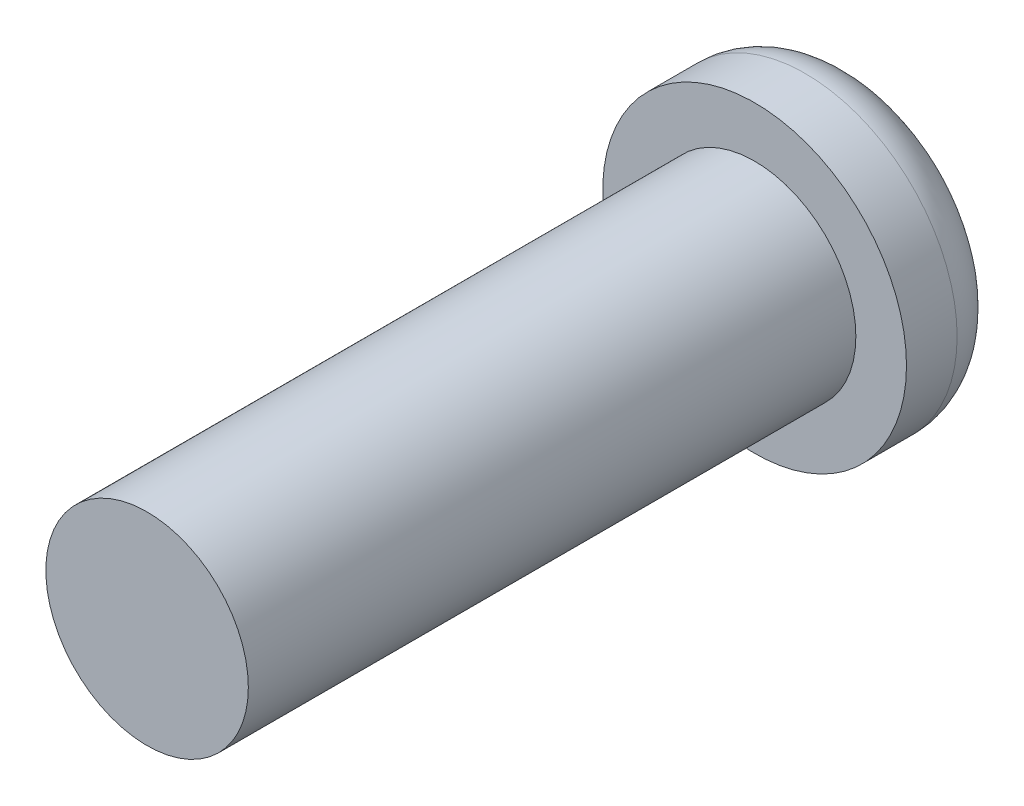
from build123d import *

# Parameters (mm, degrees)
SKETCH1_R           = 1.5
BOSS_EXTRUDE1_DEPTH = 1
SKETCH2_R           = 1
BOSS_EXTRUDE2_DEPTH = 6
CUT_EXTRUDE1_DEPTH  = 0.75
FILLET1_R           = 0.5


with BuildPart() as part:
    # Sketch1 → Boss-Extrude1 (new body)
    with BuildSketch(Plane.XY):
        Circle(SKETCH1_R)
    extrude(amount=BOSS_EXTRUDE1_DEPTH)

    # Sketch2 → Boss-Extrude2 (add)
    with BuildSketch(Plane.XY.offset(1)):
        Circle(SKETCH2_R)
    extrude(amount=BOSS_EXTRUDE2_DEPTH)

    # Sketch3 → Cut-Extrude1 (cut)
    with BuildSketch(Plane(origin=(0, 0, 0), x_dir=(-1, 0, 0), z_dir=(0, 0, -1))):
        Polygon((0.261487369, -0.51474041), (0.576521955, -0.030915501), (0.315034587, 0.483824909), (-0.261487369, 0.51474041), (-0.576521955, 0.030915501), (-0.315034587, -0.483824909), align=None)
    extrude(amount=-CUT_EXTRUDE1_DEPTH, mode=Mode.SUBTRACT)

    # Fillet1
    fillet1_edges = [part.edges().sort_by_distance(p)[0] for p in [
        (-1.5, 0, 0),
    ]]
    fillet(fillet1_edges, radius=FILLET1_R)


solid = part.part
